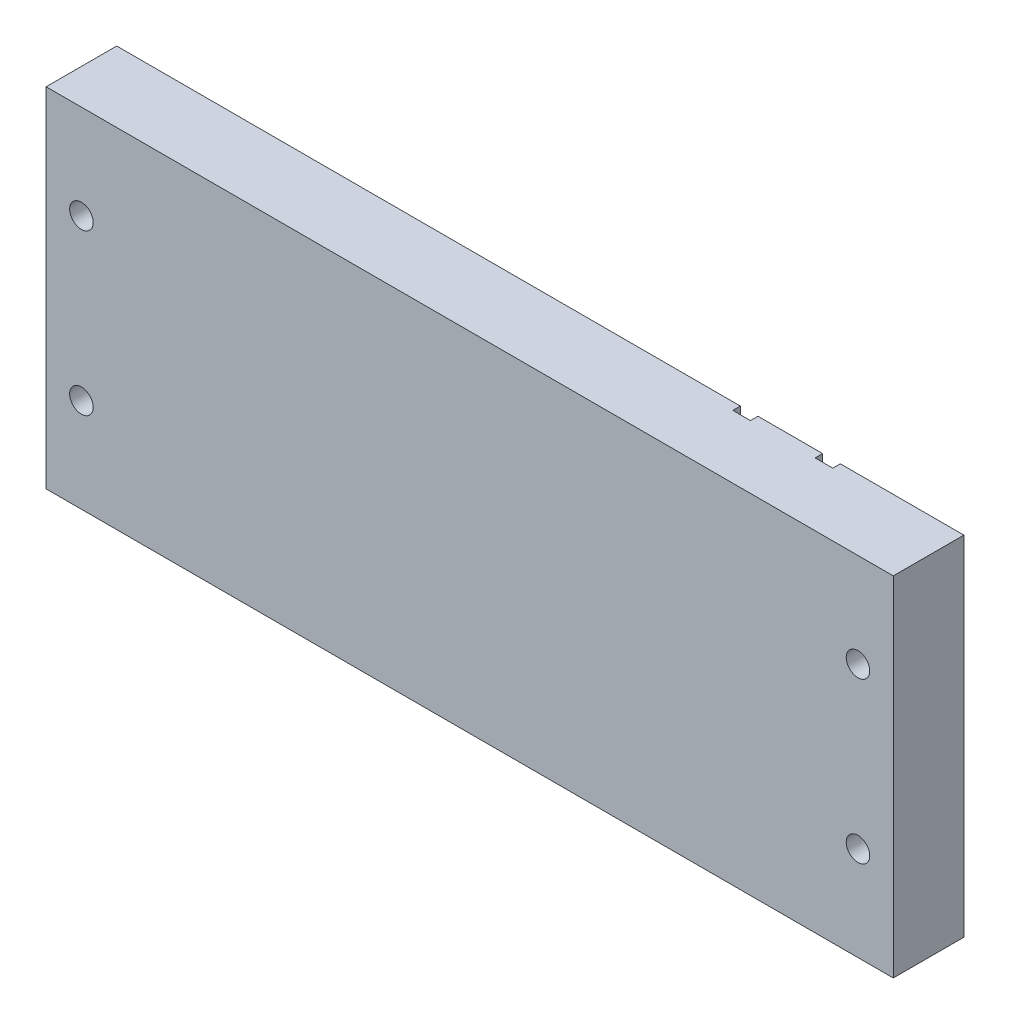
from build123d import *

# Parameters (mm, degrees)
BOSS_EXTRUDE2_DEPTH = 46.99


with BuildPart() as part:
    # 3DSketch2 → Boss-Extrude2 (new, symmetric)
    with BuildSketch(Plane(origin=(69.85, 0, -9.525), x_dir=(-0.9965457582448797, 0, 0.08304547985373997), z_dir=(0, 1, 0))):
        Polygon((0, 0), (33.222344215, -2.768528685), (33.391092631, -0.743547704), (38.137141804, -1.139051802), (37.968393389, -3.164032782), (55.370573692, -4.614214474), (55.539322108, -2.589233494), (60.285371281, -2.984737591), (60.116622866, -5.009718572), (227.810360335, -18.984196695), (229.392376726, 0), (1.582016391, 18.984196695), align=None)
    extrude(amount=BOSS_EXTRUDE2_DEPTH, both=True)

    # Sketch1 → 1/4 (0.25) Diameter Hole1 (revolve, cut)
    with BuildSketch(Plane(origin=(-149.225, -21.59, -9.525), x_dir=(0, 1, 0), z_dir=(1, 0, 0))):
        Polygon((0, 0), (0, 20.957732465), (3.175, 19.05), (3.175, 0), align=None)
    f_1_4_0_25_diameter_hole1 = revolve(axis=Axis((-149.225, -21.59, -15.875), (0, 0, 1)), mode=Mode.SUBTRACT)

    # Mirror1: 1/4 (0.25) Diameter Hole1 across plane
    add(f_1_4_0_25_diameter_hole1.mirror(Plane.ZX), mode=Mode.SUBTRACT)

    # Sketch3 → 1/4 (0.25) Diameter Hole2 (revolve, cut)
    with BuildSketch(Plane(origin=(60.325, -21.59, -9.525), x_dir=(0, 1, 0), z_dir=(1, 0, 0))):
        Polygon((0, 0), (0, 20.957732465), (3.175, 19.05), (3.175, 0), align=None)
    f_1_4_0_25_diameter_hole2 = revolve(axis=Axis((60.325, -21.59, -15.875), (0, 0, 1)), mode=Mode.SUBTRACT)

    # Mirror2: 1/4 (0.25) Diameter Hole2 across plane
    add(f_1_4_0_25_diameter_hole2.mirror(Plane.ZX), mode=Mode.SUBTRACT)


solid = part.part
